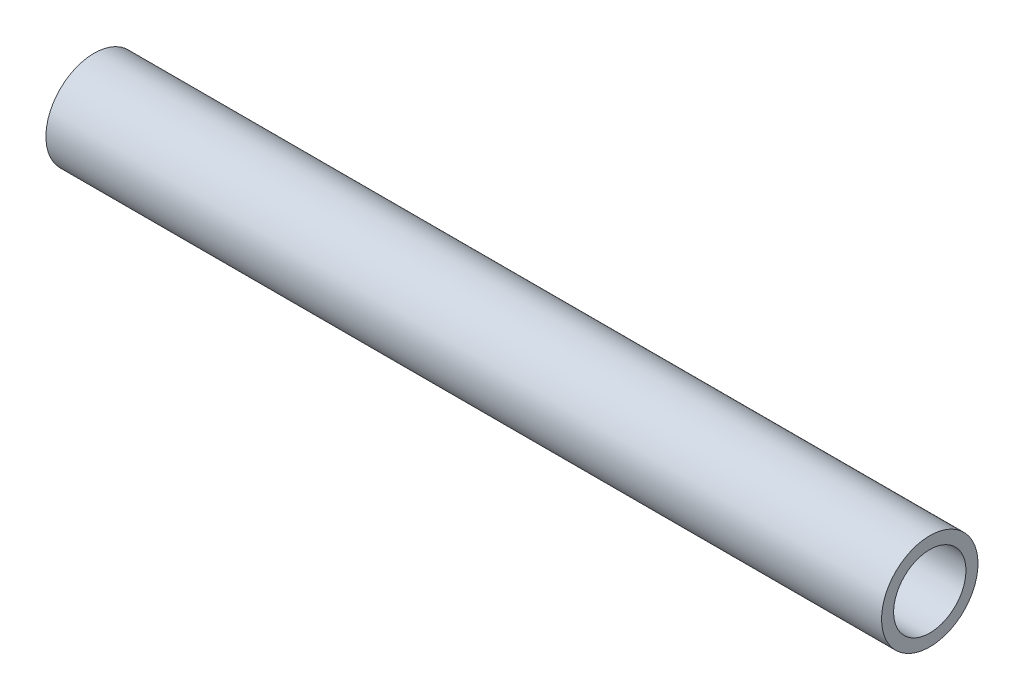
from build123d import *

# Parameters (mm, degrees)
SKETCH1_R           = 3
SKETCH1_R_2         = 2.25
BOSS_EXTRUDE1_DEPTH = 26


with BuildPart() as part:
    # Sketch1 → Boss-Extrude1 (new body, symmetric)
    with BuildSketch(Plane(origin=(0, 0, 0), x_dir=(0, 0, -1), z_dir=(1, 0, 0))):
        Circle(SKETCH1_R)
        Circle(SKETCH1_R_2, mode=Mode.SUBTRACT)
    extrude(amount=BOSS_EXTRUDE1_DEPTH, both=True)


solid = part.part
